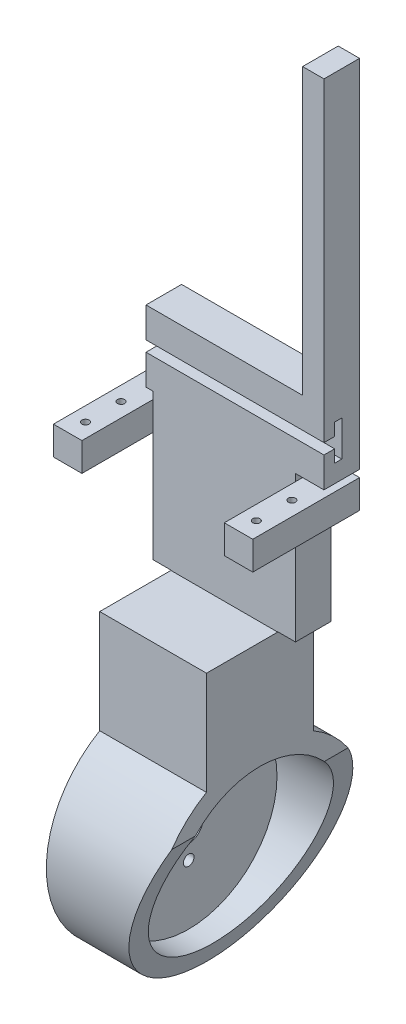
from build123d import *

# Parameters (mm, degrees)
BOSS_EXTRUDE1_DEPTH      = 30
CUT_EXTRUDE4_DEPTH       = 40
CUT_EXTRUDE4_DEPTH_BACK  = 40
BOSS_EXTRUDE2_DEPTH      = 15
BOSS_EXTRUDE2_DEPTH_BACK = 15
SKETCH7_W                = 30
SKETCH7_H                = 66.933951842
SKETCH12_W               = 30
SKETCH12_H               = 41
CUT_EXTRUDE7_DEPTH       = 20
SKETCH13_W               = 40
SKETCH13_H               = 41
BOSS_EXTRUDE4_DEPTH      = 10
BOSS_EXTRUDE5_DEPTH      = 20
BOSS_EXTRUDE5_DEPTH_BACK = 10
SKETCH15_W               = 8
SKETCH15_H               = 8
SKETCH17_R               = 1
CUT_EXTRUDE9_DEPTH       = 30
SKETCH18_R               = 24.806306278
CUT_EXTRUDE10_DEPTH      = 20
SKETCH19_R               = 4
SKETCH19_R_2             = 1.5
CUT_EXTRUDE11_DEPTH      = 30
SKETCH20_W               = 56
SKETCH20_H               = 100
BOSS_EXTRUDE6_DEPTH      = 10
SKETCH24_W               = 50
SKETCH24_H               = 80
CUT_EXTRUDE13_DEPTH      = 20
CUT_EXTRUDE14_DEPTH      = 70
SKETCH30_W               = 6
SKETCH30_H               = 20
CUT_EXTRUDE15_DEPTH      = 30


with BuildPart() as part:
    # Sketch2 → Boss-Extrude1 (new body)
    with BuildSketch(Plane(origin=(0, 0, 0), x_dir=(0, 0, -1), z_dir=(1, 0, 0))):
        with BuildLine():
            Line((-15, 35), (15, 35))
            Line((15, 35), (15, -35))
            ThreePointArc((15, -35), (0, -90.980762114), (-15, -35))
            Line((-15, -35), (-15, 35))
        make_face()
    extrude(amount=BOSS_EXTRUDE1_DEPTH)

    # Sketch6 → Cut-Extrude4 (cut, two sides: drawn at the far end of the back side and taken through both)
    with BuildSketch(Plane.XY.offset(-CUT_EXTRUDE4_DEPTH_BACK)):
        Polygon((15, 35), (30, -15.145060683), (30, -44.036502572), (15, -91.543130052), (48.566296189, -91.543130052), (48.566296189, 35), align=None)
    extrude(amount=CUT_EXTRUDE4_DEPTH + CUT_EXTRUDE4_DEPTH_BACK, mode=Mode.SUBTRACT)

    # Sketch7 → Boss-Extrude2 (add, two sides: drawn at the far end of the back side and taken through both)
    with BuildSketch(Plane.XY.offset(-BOSS_EXTRUDE2_DEPTH_BACK)):
        with Locations((15, 1.533024079)):
            Rectangle(SKETCH7_W, SKETCH7_H)
    extrude(amount=BOSS_EXTRUDE2_DEPTH + BOSS_EXTRUDE2_DEPTH_BACK)

    # Sketch12 → Cut-Extrude7 (cut)
    with BuildSketch(Plane.XY.offset(15)):
        with Locations((15, 14.5)):
            Rectangle(SKETCH12_W, SKETCH12_H)
    extrude(amount=-CUT_EXTRUDE7_DEPTH, mode=Mode.SUBTRACT)

    # Sketch13 → Boss-Extrude4 (add)
    with BuildSketch(Plane.XY.offset(-5)):
        with Locations((15, 14.596252504)):
            Rectangle(SKETCH13_W, SKETCH13_H)
    extrude(amount=-BOSS_EXTRUDE4_DEPTH)

    # Sketch15 → Boss-Extrude5 (add, two sides: drawn at the far end of the back side and taken through both)
    with BuildSketch(Plane.XY.offset(-5).offset(-BOSS_EXTRUDE5_DEPTH_BACK)):
        with Locations((39, 29.096252504)):
            Rectangle(SKETCH15_W, SKETCH15_H)
        with Locations((-9, 29.096252504)):
            Rectangle(SKETCH15_W, SKETCH15_H)
    extrude(amount=BOSS_EXTRUDE5_DEPTH + BOSS_EXTRUDE5_DEPTH_BACK)

    # Sketch17 → Cut-Extrude9 (cut)
    with BuildSketch(Plane(origin=(0, 33.096252504, 0), x_dir=(1, 0, 0), z_dir=(0, 1, 0))):
        with Locations((39, 0)):
            Circle(SKETCH17_R)
        with Locations((39, -10)):
            Circle(SKETCH17_R)
        with Locations((-9, 0)):
            Circle(SKETCH17_R)
        with Locations((-9, -10)):
            Circle(SKETCH17_R)
    extrude(amount=-CUT_EXTRUDE9_DEPTH, mode=Mode.SUBTRACT)

    # Sketch18 → Cut-Extrude10 (cut)
    with BuildSketch(Plane(origin=(30, 0, 0), x_dir=(0, 0, -1), z_dir=(1, 0, 0))):
        with Locations((0, -60.980762114)):
            Circle(SKETCH18_R)
    extrude(amount=-CUT_EXTRUDE10_DEPTH, mode=Mode.SUBTRACT)

    # Sketch19 → Cut-Extrude11 (cut)
    with BuildSketch(Plane(origin=(30, 0, 0), x_dir=(0, 0, -1), z_dir=(1, 0, 0))):
        with Locations((0, -60.980762114)):
            Circle(SKETCH19_R)
        with Locations((0, -52.980762114)):
            Circle(SKETCH19_R_2)
        with Locations((0, -68.980762114)):
            Circle(SKETCH19_R_2)
    extrude(amount=-CUT_EXTRUDE11_DEPTH, mode=Mode.SUBTRACT)

    # Sketch20 → Boss-Extrude6 (add)
    with BuildSketch(Plane.XY.offset(-5)):
        with Locations((15, 85.096252504)):
            Rectangle(SKETCH20_W, SKETCH20_H)
    extrude(amount=-BOSS_EXTRUDE6_DEPTH)

    # Sketch24 → Cut-Extrude13 (cut)
    with BuildSketch(Plane.XY.offset(-5)):
        with Locations((12, 95.096252504)):
            Rectangle(SKETCH24_W, SKETCH24_H)
    extrude(amount=-CUT_EXTRUDE13_DEPTH, mode=Mode.SUBTRACT)

    # Sketch25 → Cut-Extrude14 (cut)
    with BuildSketch(Plane(origin=(43, 0, 0), x_dir=(0, 0, -1), z_dir=(1, 0, 0))):
        Polygon((10, 50.096252504), (8, 50.096252504), (8, 46.596252504), (3.330307532, 46.596252504), (3.330307532, 43.596252504), (8, 43.596252504), (8, 40.096252504), (10, 40.096252504), align=None)
    extrude(amount=-CUT_EXTRUDE14_DEPTH, mode=Mode.SUBTRACT)

    # Sketch30 → Cut-Extrude15 (cut)
    with BuildSketch(Plane.XY.offset(-5)):
        with Locations((-10, 45.096252504)):
            Rectangle(SKETCH30_W, SKETCH30_H)
    extrude(amount=-CUT_EXTRUDE15_DEPTH, mode=Mode.SUBTRACT)


solid = part.part
